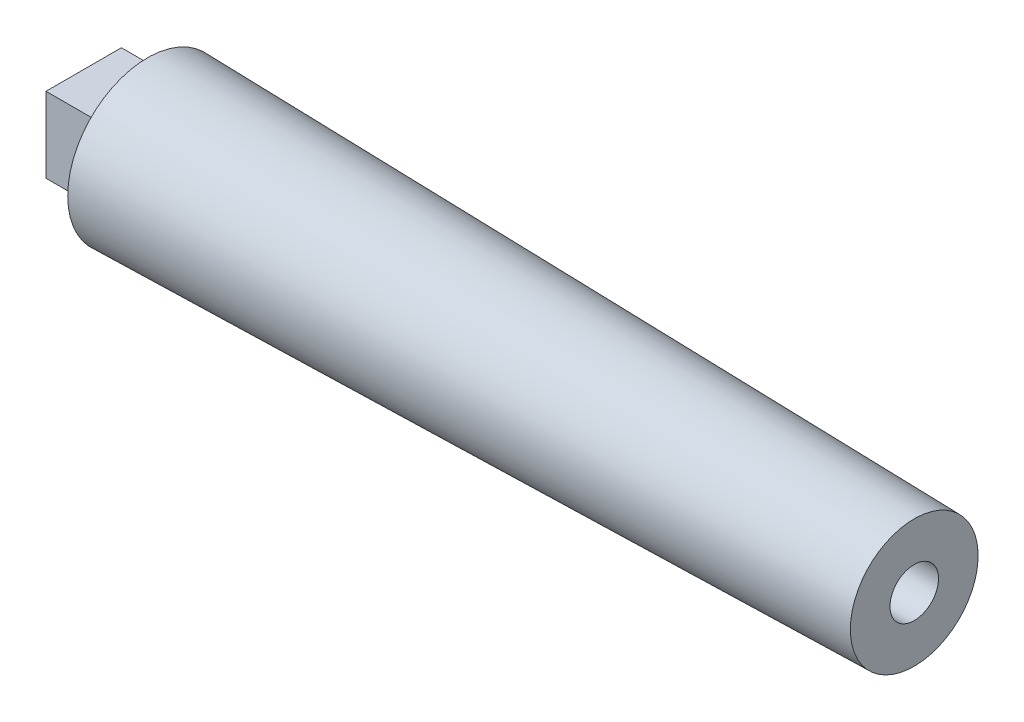
from build123d import *

# Parameters (mm, degrees)
SKETCH2_R           = 4.826
CUT_EXTRUDE1_DEPTH  = 25.4
SKETCH3_W           = 14.986
SKETCH3_H           = 14.986
BOSS_EXTRUDE1_DEPTH = 12.7


with BuildPart() as part:
    # Sketch1 → Revolve1 (revolve)
    with BuildSketch(Plane.XY):
        Polygon((0, 0), (152.4, 0), (152.4, 12.7), (0, 15.875), align=None)
    revolve(axis=Axis((0, 0, 0), (1, 0, 0)))

    # Sketch2 → Cut-Extrude1 (cut)
    with BuildSketch(Plane(origin=(152.4, 0, 0), x_dir=(0, 0, -1), z_dir=(1, 0, 0))):
        Circle(SKETCH2_R)
    extrude(amount=-CUT_EXTRUDE1_DEPTH, mode=Mode.SUBTRACT)

    # Sketch3 → Boss-Extrude1 (add)
    with BuildSketch(Plane.ZY):
        Rectangle(SKETCH3_W, SKETCH3_H)
    extrude(amount=BOSS_EXTRUDE1_DEPTH)


solid = part.part
